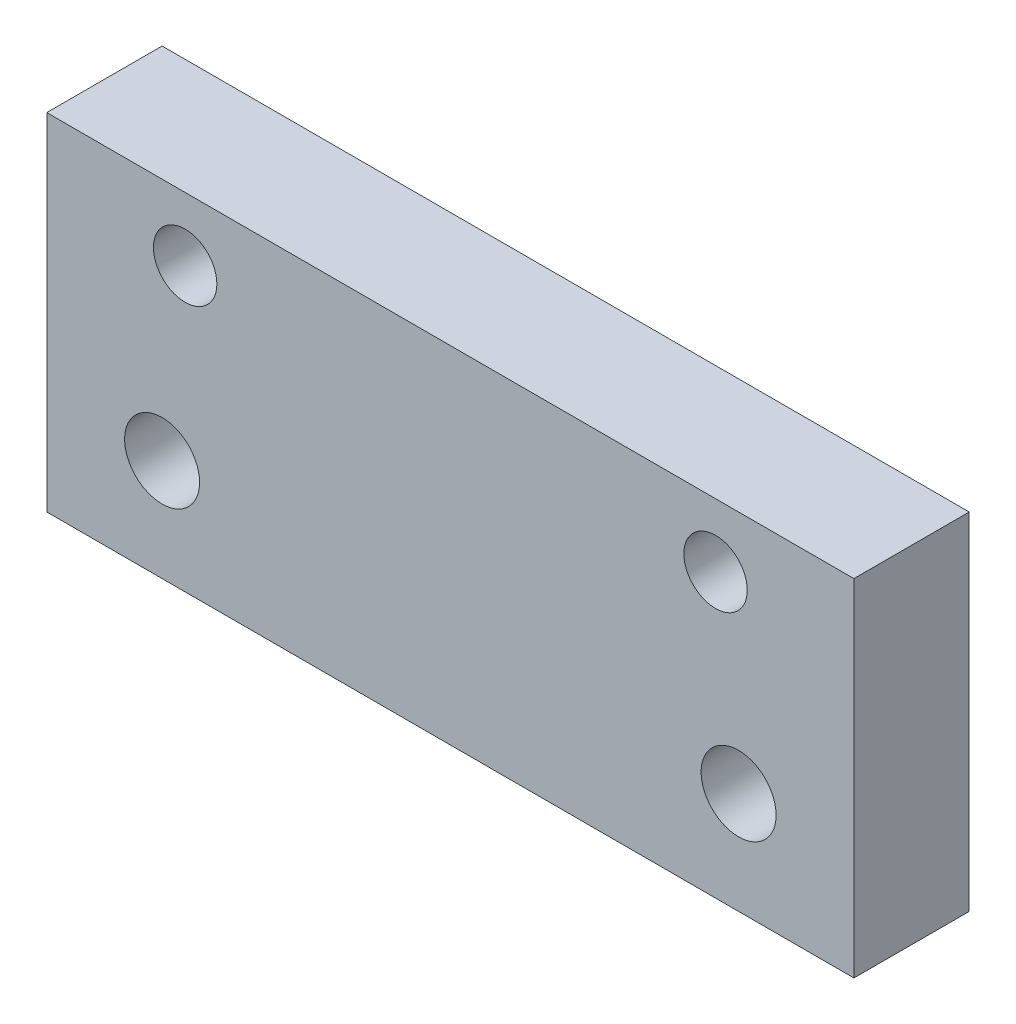
from build123d import *

# Parameters (mm, degrees)
SKETCH1_W           = 70
SKETCH1_H           = 30
SKETCH1_R           = 3.25
SKETCH1_R_2         = 2.75
BOSS_EXTRUDE1_DEPTH = 10
SKETCH3_R           = 5
CUT_EXTRUDE1_DEPTH  = 5.4


with BuildPart() as part:
    # Sketch1 → Boss-Extrude1 (new body)
    with BuildSketch(Plane.XY):
        Rectangle(SKETCH1_W, SKETCH1_H)
        with Locations((-25, -6.150362319)):
            Circle(SKETCH1_R, mode=Mode.SUBTRACT)
        with Locations((25, -6.150362319)):
            Circle(SKETCH1_R, mode=Mode.SUBTRACT)
        with Locations((-23, 9.5)):
            Circle(SKETCH1_R_2, mode=Mode.SUBTRACT)
        with Locations((23, 9.5)):
            Circle(SKETCH1_R_2, mode=Mode.SUBTRACT)
    extrude(amount=BOSS_EXTRUDE1_DEPTH)

    # Sketch3 → Cut-Extrude1 (cut)
    with BuildSketch(Plane(origin=(0, 0, 0), x_dir=(-1, 0, 0), z_dir=(0, 0, -1))):
        with Locations((-23, 9.5)):
            Circle(SKETCH3_R)
        with Locations((23, 9.5)):
            Circle(SKETCH3_R)
    extrude(amount=-CUT_EXTRUDE1_DEPTH, mode=Mode.SUBTRACT)


solid = part.part
